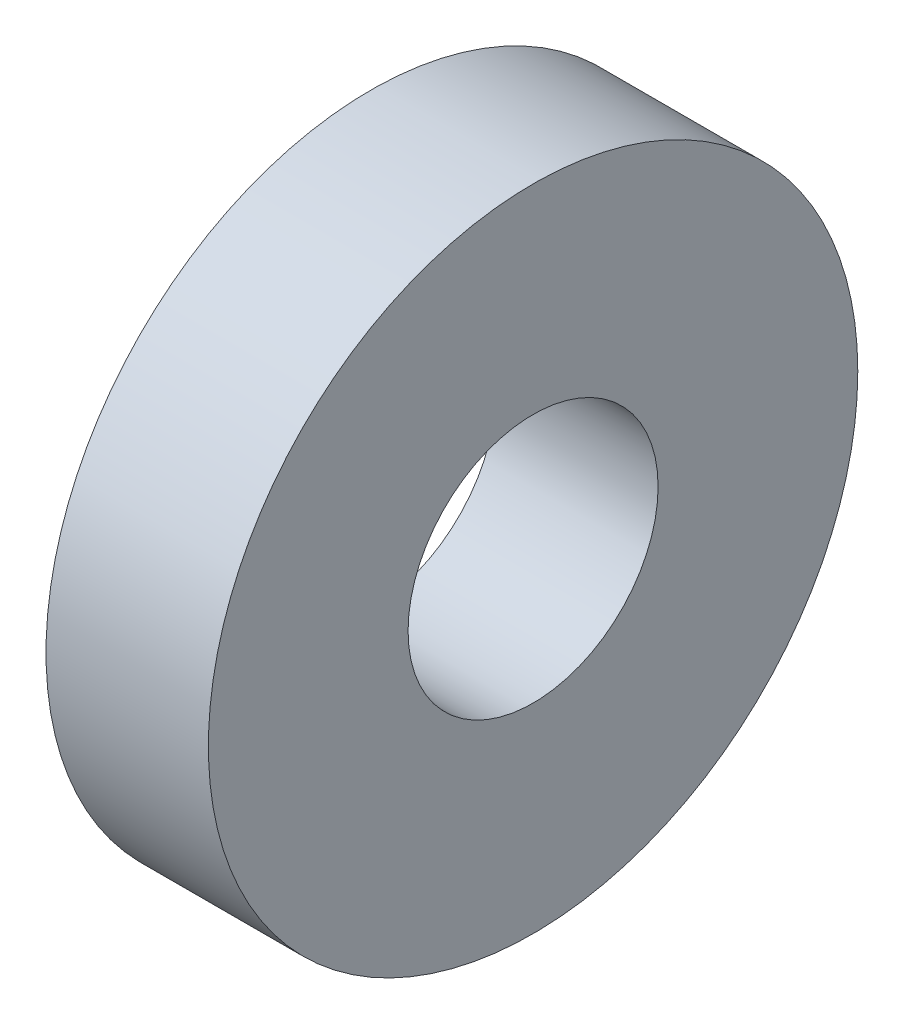
from build123d import *

# Parameters (mm, degrees)
SKETCH1_R           = 12.7
SKETCH1_R_2         = 4.8895
BOSS_EXTRUDE1_DEPTH = 6.35


with BuildPart() as part:
    # Sketch1 → Boss-Extrude1 (new body)
    with BuildSketch(Plane(origin=(0, 0, 0), x_dir=(0, 0, -1), z_dir=(1, 0, 0))):
        Circle(SKETCH1_R)
        Circle(SKETCH1_R_2, mode=Mode.SUBTRACT)
    extrude(amount=BOSS_EXTRUDE1_DEPTH)


solid = part.part
